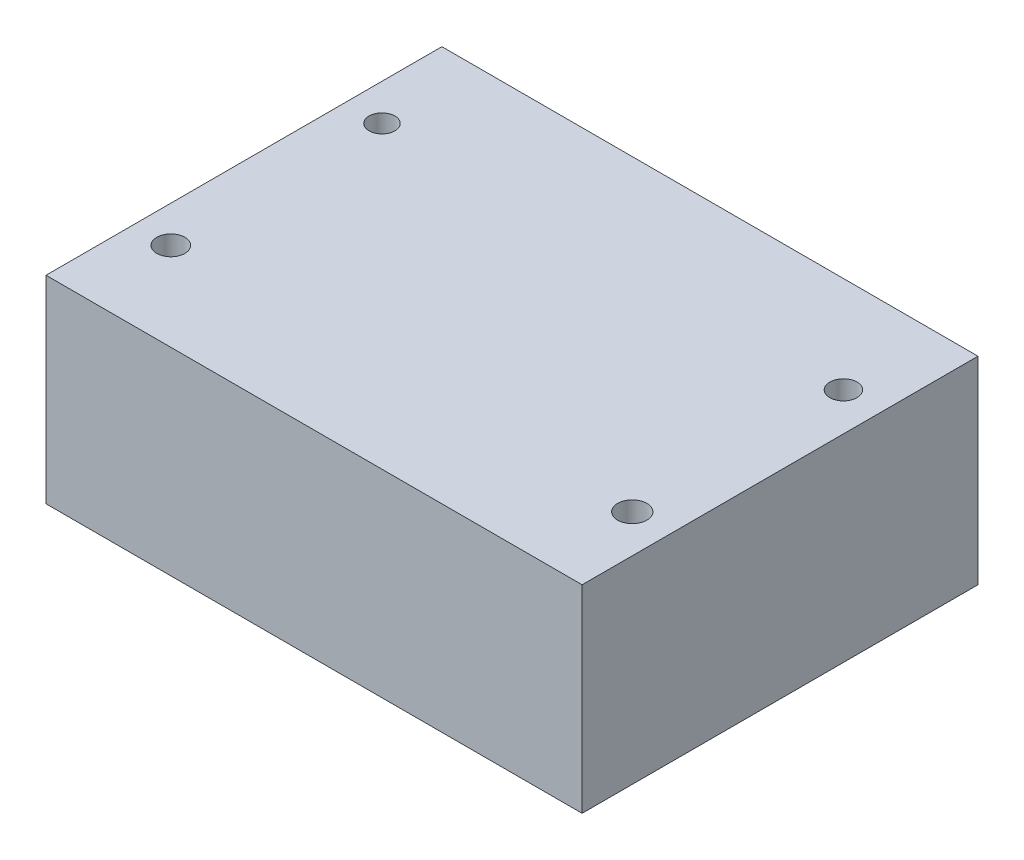
from build123d import *

# Parameters (mm, degrees)
SKETCH1_W           = 65
SKETCH1_H           = 48
BOSS_EXTRUDE2_DEPTH = 24
SKETCH2_R           = 1.566039554
SKETCH2_R_2         = 1.648224053
SKETCH2_R_3         = 1.77218792
SKETCH2_R_4         = 1.702058057
CUT_EXTRUDE1_DEPTH  = 30


with BuildPart() as part:
    # Sketch1 → Boss-Extrude2 (new body)
    with BuildSketch(Plane(origin=(0, 0, 0), x_dir=(1, 0, 0), z_dir=(0, 1, 0))):
        with Locations((0, 10.821428571)):
            Rectangle(SKETCH1_W, SKETCH1_H)
    extrude(amount=BOSS_EXTRUDE2_DEPTH)

    # Sketch2 → Cut-Extrude1 (cut)
    with BuildSketch(Plane(origin=(0, 24, 0), x_dir=(1, 0, 0), z_dir=(0, 1, 0))):
        with Locations((-28.072146294, 23.129373379)):
            Circle(SKETCH2_R)
        with Locations((27.875263864, 23.129373379)):
            Circle(SKETCH2_R_2)
        with Locations((27.875263864, -2.472714992)):
            Circle(SKETCH2_R_3)
        with Locations((-28.072146294, -2.472714992)):
            Circle(SKETCH2_R_4)
    extrude(amount=-CUT_EXTRUDE1_DEPTH, mode=Mode.SUBTRACT)


solid = part.part
